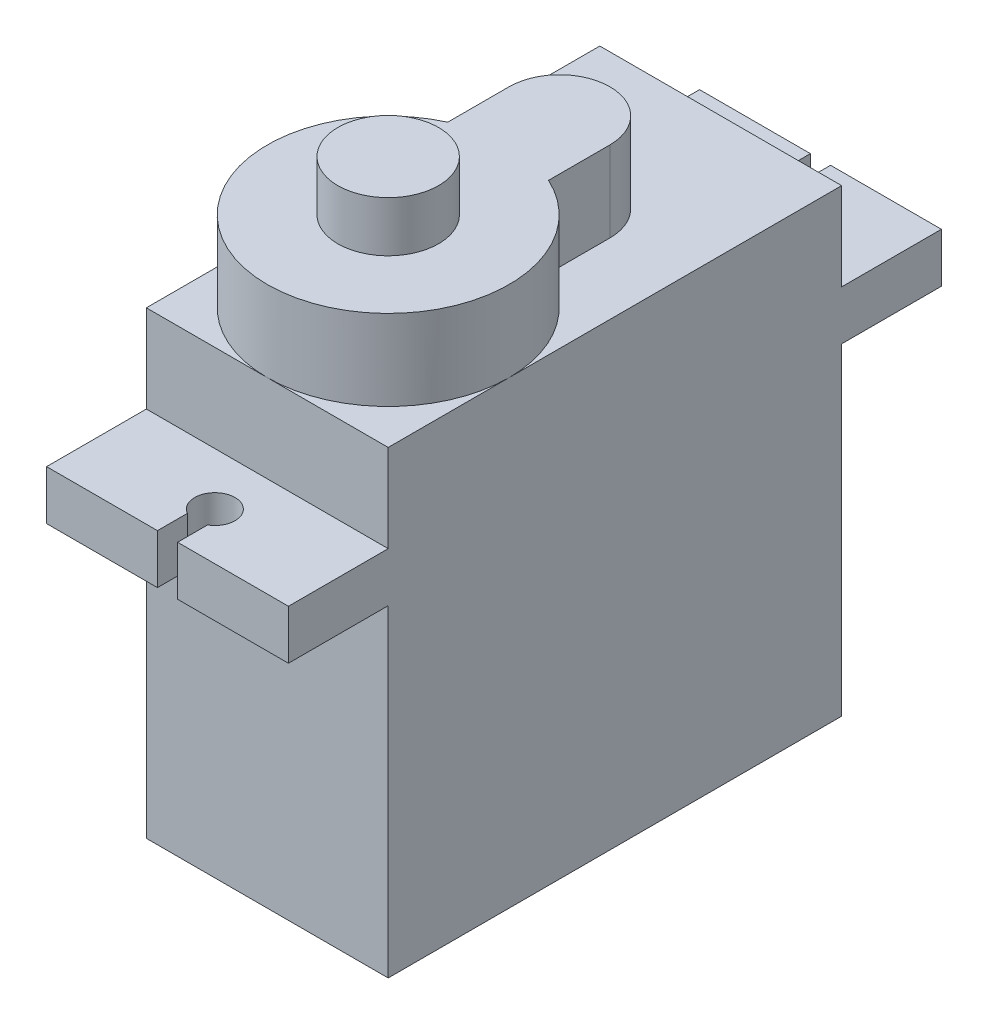
from build123d import *

# Parameters (mm, degrees)
EXTRUSION1_DEPTH = 12
EXTRUSION2_DEPTH = 12.6
EXTRUSION3_DEPTH = 4
SKETCH4_R        = 2.5
EXTRUSION4_DEPTH = 2.5


with BuildPart() as part:
    # Sketch1 → Extrusion1 (new body)
    with BuildSketch(Plane.YZ):
        Polygon((0, 0), (0, 11.25), (16, 11.25), (16, 16.2), (18.45, 16.2), (18.45, 11.25), (22.8, 11.25), (22.8, 0), (22.8, -11.25), (18.45, -11.25), (18.45, -16.2), (16, -16.2), (16, -11.25), (0, -11.25), align=None)
    extrude(amount=EXTRUSION1_DEPTH)

    # Sketch2 → Extrusion2 (cut)
    with BuildSketch(Plane(origin=(0, 18.45, 0), x_dir=(-1, 0, 0), z_dir=(0, 1, 0))):
        with BuildLine():
            Line((-6.5, -14.716025404), (-6.5, -16.2))
            Line((-6.5, -16.2), (-5.5, -16.2))
            Line((-5.5, -16.2), (-5.5, -14.716025404))
            ThreePointArc((-5.5, -14.716025404), (-6, -12.85), (-6.5, -14.716025404))
        make_face()
        with BuildLine():
            Line((-6.5, 14.716025404), (-6.5, 16.2))
            Line((-6.5, 16.2), (-5.5, 16.2))
            Line((-5.5, 16.2), (-5.5, 14.716025404))
            ThreePointArc((-5.5, 14.716025404), (-6, 12.85), (-6.5, 14.716025404))
        make_face()
    extrude(amount=-EXTRUSION2_DEPTH, mode=Mode.SUBTRACT)

    # Sketch3 → Extrusion3 (add)
    with BuildSketch(Plane(origin=(0, 22.8, 0), x_dir=(-1, 0, 0), z_dir=(0, 1, 0))):
        with BuildLine():
            Line((-8.5, -0.204356057), (-8.5, -3.25))
            ThreePointArc((-8.5, -3.25), (-6, -5.75), (-3.5, -3.25))
            Line((-3.5, -3.25), (-3.5, -0.204356057))
            ThreePointArc((-3.5, -0.204356057), (-6, 11.25), (-8.5, -0.204356057))
        make_face()
    extrude(amount=EXTRUSION3_DEPTH)

    # Sketch4 → Extrusion4 (add)
    with BuildSketch(Plane(origin=(0, 26.8, 11.25), x_dir=(1, 0, 0), z_dir=(0, 1, 0))):
        with Locations((6, 6)):
            Circle(SKETCH4_R)
    extrude(amount=EXTRUSION4_DEPTH)


solid = part.part
